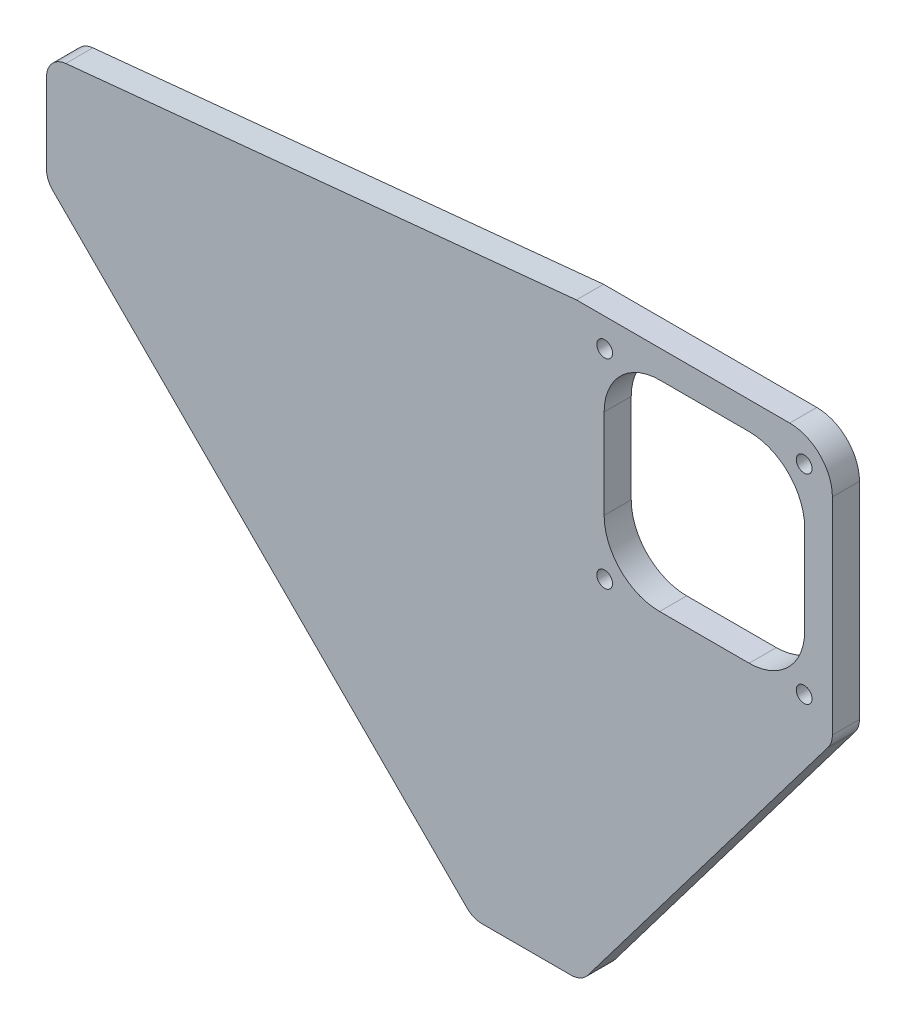
from build123d import *

# Parameters (mm, degrees)
BOSS_EXTRUDE1_DEPTH = 6.35
BOSS_EXTRUDE2_DEPTH = 6.35
FILLET1_R           = 10
FILLET2_R           = 5
CUT_EXTRUDE1_DEPTH  = 7.35
SKETCH4_R           = 1.85
CUT_EXTRUDE2_DEPTH  = 7.35


with BuildPart() as part:
    # Sketch1 → Boss-Extrude1 (new body)
    with BuildSketch(Plane.XY):
        Polygon((-100, 0), (0, -100), (25.4, -100), (25.4, 25.4), (-100, 25.4), align=None)
    extrude(amount=BOSS_EXTRUDE1_DEPTH)

    # Sketch2 → Boss-Extrude2 (add)
    with BuildSketch(Plane.XY):
        Polygon((24.2, 37.7), (84.2, 37.7), (84.2, -22.3), (25.4, -100), (24.2, -22.3), (-100, 25.4), align=None)
    extrude(amount=BOSS_EXTRUDE2_DEPTH)

    # Fillet1
    fillet1_edges = [part.edges().sort_by_distance(p)[0] for p in [
        (84.2, 37.7, 3.175),
    ]]
    fillet(fillet1_edges, radius=FILLET1_R)

    # Fillet2
    fillet2_edges = [part.edges().sort_by_distance(p)[0] for p in [
        (84.2, -22.3, 3.175),
        (25.4, -100, 3.175),
        (0, -100, 3.175),
        (-100, 0, 3.175),
        (-100, 25.4, 3.175),
    ]]
    fillet(fillet2_edges, radius=FILLET2_R)

    # Sketch3 → Cut-Extrude1 (cut, through all)
    with BuildSketch(Plane.XY.offset(6.35)):
        with BuildLine():
            Line((43.7, 31.2), (64.7, 31.2))
            ThreePointArc((64.7, 31.2), (73.892388155, 27.392388155), (77.7, 18.2))
            Line((77.7, 18.2), (77.7, -2.8))
            ThreePointArc((77.7, -2.8), (73.892388155, -11.992388155), (64.7, -15.8))
            Line((64.7, -15.8), (43.7, -15.8))
            ThreePointArc((43.7, -15.8), (34.507611845, -11.992388155), (30.7, -2.8))
            Line((30.7, -2.8), (30.7, 18.2))
            ThreePointArc((30.7, 18.2), (34.507611845, 27.392388155), (43.7, 31.2))
        make_face()
    extrude(amount=-CUT_EXTRUDE1_DEPTH, mode=Mode.SUBTRACT)

    # Sketch4 → Cut-Extrude2 (cut, through all)
    with BuildSketch(Plane(origin=(0, 0, 0), x_dir=(-1, 0, 0), z_dir=(0, 0, -1))):
        with Locations((-77.581727984, 31.081727984)):
            Circle(SKETCH4_R)
        with Locations((-30.821727984, 31.081727984)):
            Circle(SKETCH4_R)
        with Locations((-30.821727984, -15.678272016)):
            Circle(SKETCH4_R)
        with Locations((-77.581727984, -15.678272016)):
            Circle(SKETCH4_R)
    extrude(amount=-CUT_EXTRUDE2_DEPTH, mode=Mode.SUBTRACT)


solid = part.part
